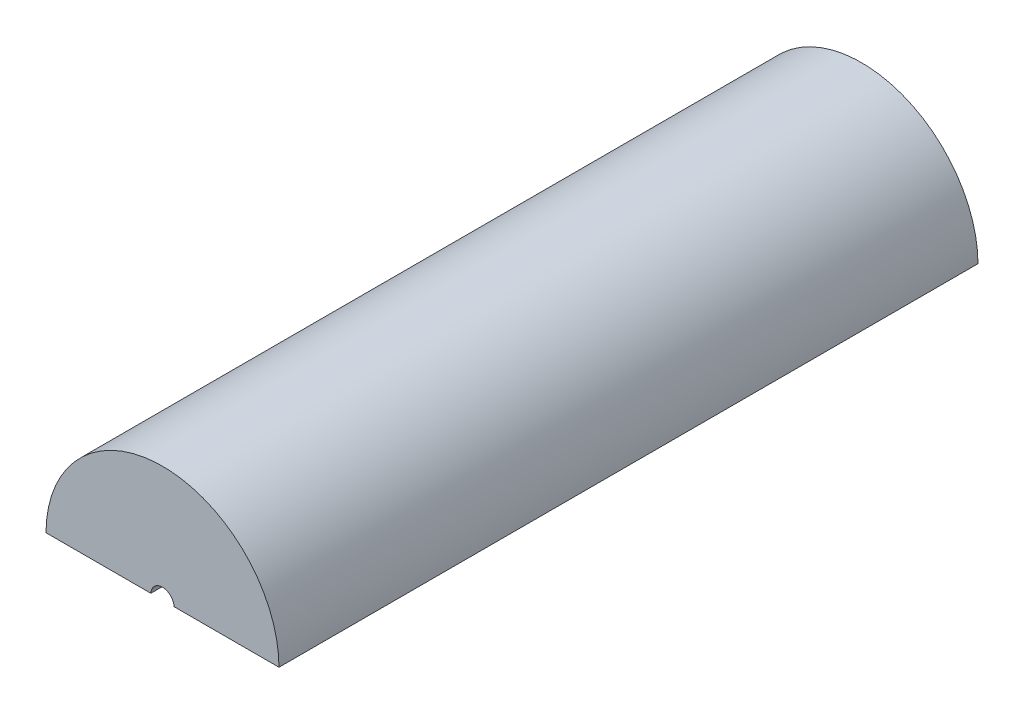
from build123d import *

# Parameters (mm, degrees)
ESQUISSE1_R             = 20
BOSS_EXTRU_1_DEPTH      = 120
ESQUISSE3_R             = 16
ENL_V_MAT_EXTRU_1_DEPTH = 90
ENL_V_MAT_EXTRU_3_DEPTH = 140
ESQUISSE9_R             = 2
ENL_V_MAT_EXTRU_4_DEPTH = 10


with BuildPart() as part:
    # Esquisse1 → Boss.-Extru.1 (new body)
    with BuildSketch(Plane.XY):
        Circle(ESQUISSE1_R)
    extrude(amount=-BOSS_EXTRU_1_DEPTH)

    # Esquisse3 → Enlèv. mat.-Extru.1 (cut)
    with BuildSketch(Plane.XY.offset(-5)):
        Circle(ESQUISSE3_R)
    extrude(amount=-ENL_V_MAT_EXTRU_1_DEPTH, mode=Mode.SUBTRACT)

    # Esquisse6 → Enlèv. mat.-Extru.3 (cut)
    with BuildSketch(Plane(origin=(0, 0, -120), x_dir=(-1, 0, 0), z_dir=(0, 0, -1))):
        Polygon((-21.427885592, 0), (-21.427885592, -0.1), (22.282526064, -0.1), (22.282526064, 0.1), (-21.427885592, 0.1), align=None)
    extrude(amount=-ENL_V_MAT_EXTRU_3_DEPTH, mode=Mode.SUBTRACT)


with BuildPart() as body_2:
    # of the pieces the cut leaves, the one that is kept (enl_v_mat_extru_3_keep)
    add(part.part.solids().sort_by_distance((19.999749998, 0.1, 0))[0])

    # Esquisse8 → Enlèvement de matière-Révolution3 (revolve, cut)
    with BuildSketch(Plane.XZ.offset(-0.1)):
        with BuildLine():
            Line((-15.999687497, -95), (15.999687497, -95))
            ThreePointArc((15.999687497, -95), (0, -79.000312503), (-15.999687497, -95))
        make_face()
    revolve(axis=Axis((-15.999687497, 0.1, -95), (1, 0, 0)), mode=Mode.SUBTRACT)

    # Esquisse9 → Enlèv. mat.-Extru.4 (cut)
    with BuildSketch(Plane.XY):
        Circle(ESQUISSE9_R)
    extrude(amount=-ENL_V_MAT_EXTRU_4_DEPTH, mode=Mode.SUBTRACT)


solid = body_2.part
